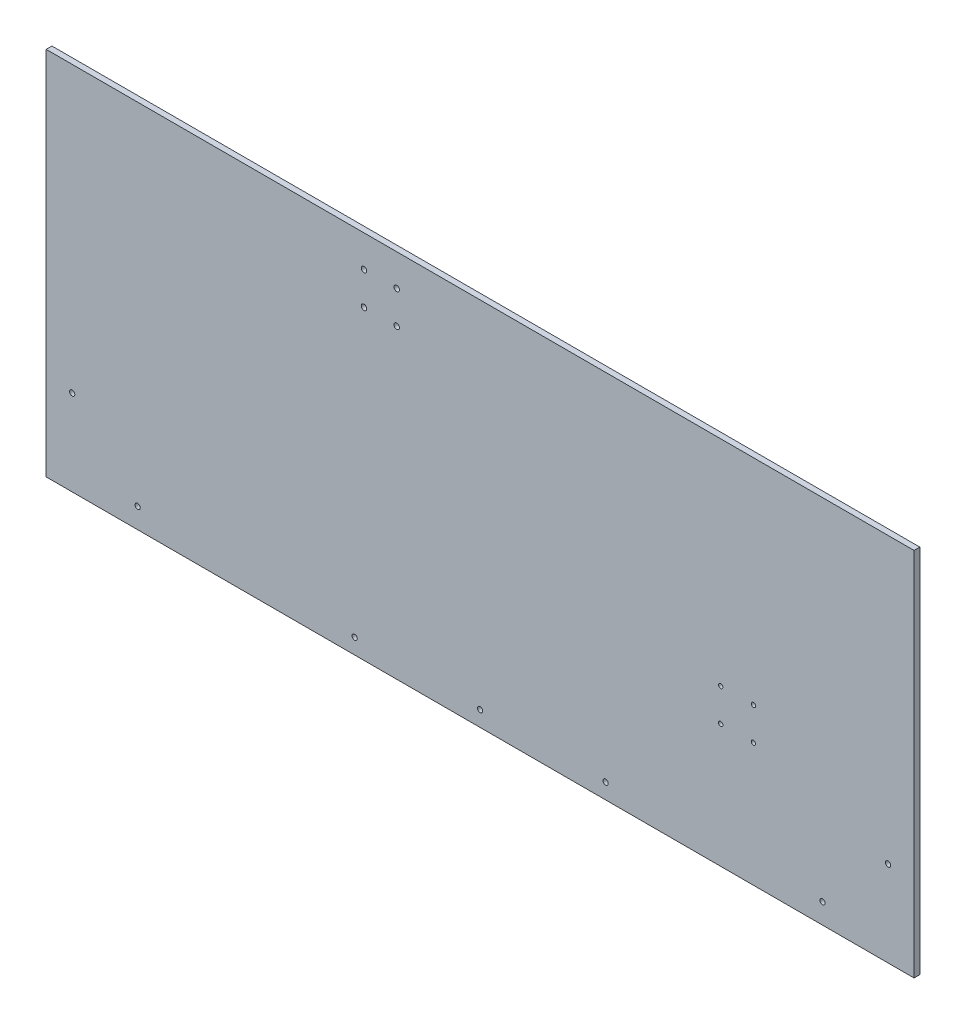
from build123d import *

# Parameters (mm, degrees)
SKETCH1_W                 = 714.375
SKETCH1_H                 = 304.8
BOSS_EXTRUDE1_DEPTH       = 4.7625
CUT_EXTRUDE3_DEPTH        = 5.7625
CUT_EXTRUDE4_REACH        = 6.763
SKETCH5_R                 = 2.15265
BOSS_EXTRUDE2_START       = -638.8354
SKETCH7_W                 = 4.7625
SKETCH7_H                 = 304.8
BOSS_EXTRUDE2_DEPTH       = 563.2958
F_8_CLEARANCE_HOLE1_D     = 4.3053
F_8_CLEARANCE_HOLE1_DEPTH = 74.422
F_8_CLEARANCE_HOLE1_TIP   = 1.293442612
F_8_CLEARANCE_HOLE2_D     = 4.3053
F_8_CLEARANCE_HOLE2_DEPTH = 74.422
F_8_CLEARANCE_HOLE2_TIP   = 1.293442612
F_8_CLEARANCE_HOLE3_D     = 4.4958
F_8_CLEARANCE_HOLE3_DEPTH = 74.422
F_8_CLEARANCE_HOLE3_TIP   = 1.350674586
SKETCH16_R                = 1.778
CUT_EXTRUDE5_DEPTH        = 4.7625


with BuildPart() as part:
    # Sketch1 → Boss-Extrude1 (new body)
    with BuildSketch(Plane.XY):
        Rectangle(SKETCH1_W, SKETCH1_H)
    extrude(amount=BOSS_EXTRUDE1_DEPTH)

    # Sketch4 → Cut-Extrude3 (cut, through all)
    with BuildSketch(Plane.XY.offset(4.7625)):
        with BuildLine():
            Line((277.1521, 103.505), (277.1521, 112.395))
            ThreePointArc((277.1521, 112.395), (279.4, 114.6429), (281.6479, 112.395))
            Line((281.6479, 112.395), (281.6479, 103.505))
            ThreePointArc((281.6479, 103.505), (279.4, 101.2571), (277.1521, 103.505))
        make_face()
        with BuildLine():
            Line((-277.1521, 103.505), (-277.1521, 112.395))
            ThreePointArc((-277.1521, 112.395), (-279.4, 114.6429), (-281.6479, 112.395))
            Line((-281.6479, 112.395), (-281.6479, 103.505))
            ThreePointArc((-281.6479, 103.505), (-279.4, 101.2571), (-277.1521, 103.505))
        make_face()
    extrude(amount=-CUT_EXTRUDE3_DEPTH, mode=Mode.SUBTRACT)

    # Sketch5 → Cut-Extrude4 (cut, up to next)
    with BuildSketch(Plane.XY.offset(4.7625), mode=Mode.PRIVATE) as cut_extrude4_sk1:
        with Locations((-127, -120.65)):
            Circle(SKETCH5_R)
    cut_extrude4_tool1 = extrude(cut_extrude4_sk1.sketch, amount=-CUT_EXTRUDE4_REACH, mode=Mode.PRIVATE) & part.part
    add(cut_extrude4_tool1.solids().sort_by_distance((-127, -120.65, 4.7625))[0], mode=Mode.SUBTRACT)
    # Sketch5 → Cut-Extrude4 (cut, up to next)
    with BuildSketch(Plane.XY.offset(4.7625), mode=Mode.PRIVATE) as cut_extrude4_sk2:
        with Locations((-215.9, -120.65)):
            Circle(SKETCH5_R)
    cut_extrude4_tool2 = extrude(cut_extrude4_sk2.sketch, amount=-CUT_EXTRUDE4_REACH, mode=Mode.PRIVATE) & part.part
    add(cut_extrude4_tool2.solids().sort_by_distance((-215.9, -120.65, 4.7625))[0], mode=Mode.SUBTRACT)
    # Sketch5 → Cut-Extrude4 (cut, up to next)
    with BuildSketch(Plane.XY.offset(4.7625), mode=Mode.PRIVATE) as cut_extrude4_sk3:
        with Locations((215.9, -120.65)):
            Circle(SKETCH5_R)
    cut_extrude4_tool3 = extrude(cut_extrude4_sk3.sketch, amount=-CUT_EXTRUDE4_REACH, mode=Mode.PRIVATE) & part.part
    add(cut_extrude4_tool3.solids().sort_by_distance((215.9, -120.65, 4.7625))[0], mode=Mode.SUBTRACT)
    # Sketch5 → Cut-Extrude4 (cut, up to next)
    with BuildSketch(Plane.XY.offset(4.7625), mode=Mode.PRIVATE) as cut_extrude4_sk4:
        with Locations((127, -120.65)):
            Circle(SKETCH5_R)
    cut_extrude4_tool4 = extrude(cut_extrude4_sk4.sketch, amount=-CUT_EXTRUDE4_REACH, mode=Mode.PRIVATE) & part.part
    add(cut_extrude4_tool4.solids().sort_by_distance((127, -120.65, 4.7625))[0], mode=Mode.SUBTRACT)

    # Sketch7 → Boss-Extrude2 (add)
    with BuildSketch(Plane(origin=(357.1875, 0, 0), x_dir=(0, 0, -1), z_dir=(1, 0, 0)).offset(BOSS_EXTRUDE2_START)):
        with Locations((-2.38125, 0)):
            Rectangle(SKETCH7_W, SKETCH7_H)
    extrude(amount=BOSS_EXTRUDE2_DEPTH)

    # #8 Clearance Hole1
    with Locations(Plane.XY.offset(4.7625)):
        with Locations((-335.768024484, -81.861487758), (-281.886487758, -135.743024484), (281.886487758, -135.743024484), (335.768024484, -81.861487758)):
            Hole(F_8_CLEARANCE_HOLE1_D / 2, depth=F_8_CLEARANCE_HOLE1_DEPTH)
            with Locations((0, 0, -(F_8_CLEARANCE_HOLE1_DEPTH + F_8_CLEARANCE_HOLE1_TIP / 2))):  # 118° drill point
                Cone(0, F_8_CLEARANCE_HOLE1_D / 2, F_8_CLEARANCE_HOLE1_TIP, mode=Mode.SUBTRACT)

    # #8 Clearance Hole2
    with Locations(Plane.XY.offset(4.7625)):
        with Locations((-103.251, -139.7), (0, -139.7), (103.251, -139.7)):
            Hole(F_8_CLEARANCE_HOLE2_D / 2, depth=F_8_CLEARANCE_HOLE2_DEPTH)
            with Locations((0, 0, -(F_8_CLEARANCE_HOLE2_DEPTH + F_8_CLEARANCE_HOLE2_TIP / 2))):  # 118° drill point
                Cone(0, F_8_CLEARANCE_HOLE2_D / 2, F_8_CLEARANCE_HOLE2_TIP, mode=Mode.SUBTRACT)

    # #8 Clearance Hole3
    with Locations(Plane.XY.offset(4.7625)):
        with Locations((-95.5675, 126.238), (-68.6435, 126.238), (-95.5675, 99.314), (-68.6435, 99.314)):
            Hole(F_8_CLEARANCE_HOLE3_D / 2, depth=F_8_CLEARANCE_HOLE3_DEPTH)
            with Locations((0, 0, -(F_8_CLEARANCE_HOLE3_DEPTH + F_8_CLEARANCE_HOLE3_TIP / 2))):  # 118° drill point
                Cone(0, F_8_CLEARANCE_HOLE3_D / 2, F_8_CLEARANCE_HOLE3_TIP, mode=Mode.SUBTRACT)

    # Sketch16 → Cut-Extrude5 (cut)
    with BuildSketch(Plane.XY.offset(4.7625)):
        with Locations((198.048115818, -23.867615818)):
            Circle(SKETCH16_R)
        with Locations((224.988884182, -23.867615818)):
            Circle(SKETCH16_R)
        with Locations((224.988884182, -50.808384182)):
            Circle(SKETCH16_R)
        with Locations((198.048115818, -50.808384182)):
            Circle(SKETCH16_R)
    extrude(amount=-CUT_EXTRUDE5_DEPTH, mode=Mode.SUBTRACT)


solid = part.part
